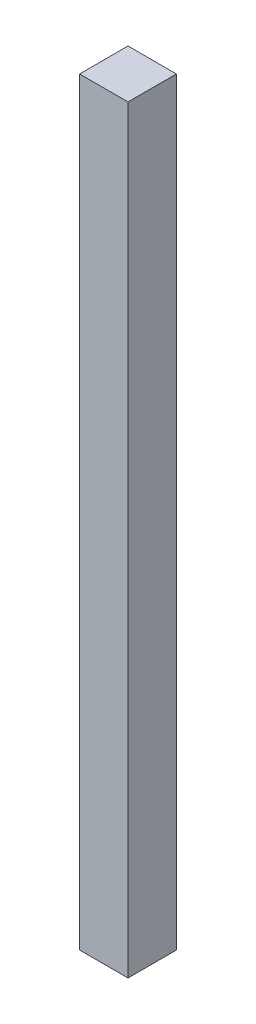
from build123d import *

# Parameters (mm, degrees)
SKETCH1_W           = 38.1
SKETCH1_H           = 596.9
BOSS_EXTRUDE1_DEPTH = 38.1


with BuildPart() as part:
    # Sketch1 → Boss-Extrude1 (new body)
    with BuildSketch(Plane.XY):
        with Locations((666.75, -336.55)):
            Rectangle(SKETCH1_W, SKETCH1_H)
    extrude(amount=BOSS_EXTRUDE1_DEPTH)


solid = part.part
